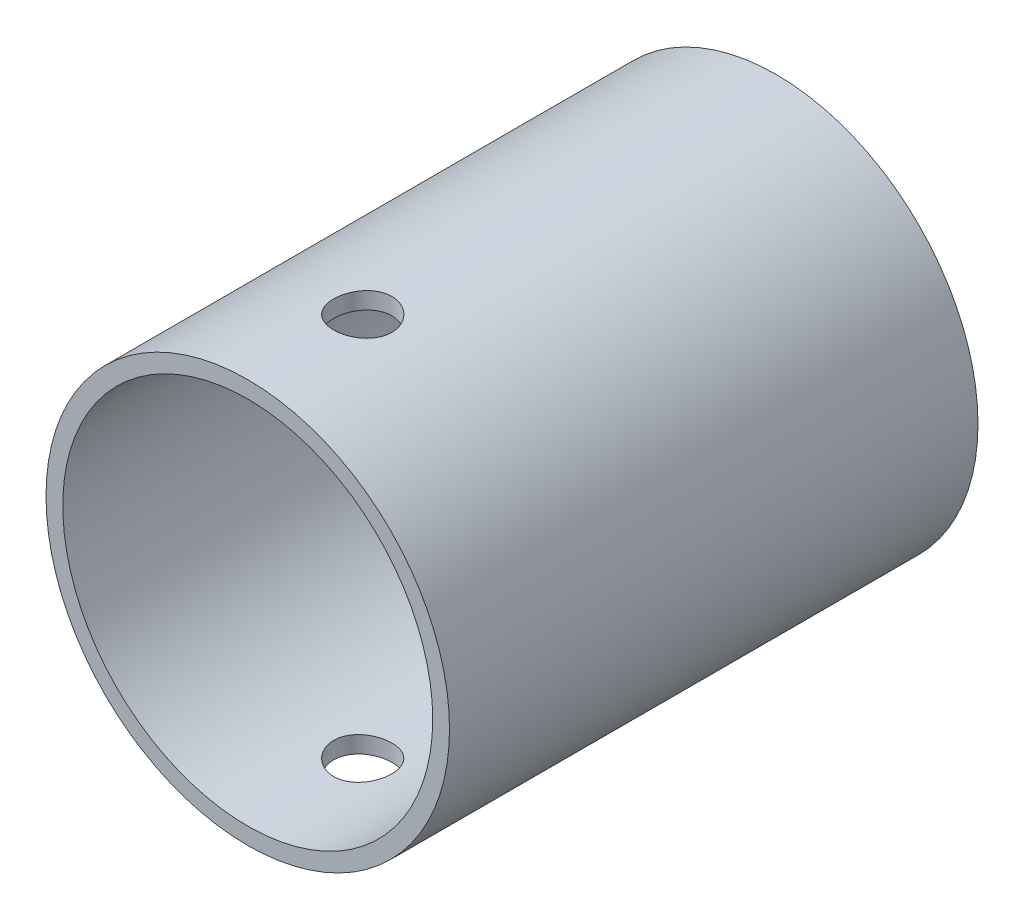
from build123d import *

# Parameters (mm, degrees)
SKETCH1_R           = 19.0875
SKETCH1_R_2         = 17.5
BOSS_EXTRUDE1_DEPTH = 50
SKETCH2_R           = 17.5
SKETCH2_R_2         = 6
BOSS_EXTRUDE2_DEPTH = 5
SKETCH3_R           = 17.5
SKETCH3_R_2         = 9
BOSS_EXTRUDE3_DEPTH = 1
SKETCH4_R           = 17.5
SKETCH4_R_2         = 10
BOSS_EXTRUDE4_DEPTH = 12
SKETCH7_W           = 2.75
SKETCH7_H           = 19.0875


with BuildPart() as part:
    # Sketch1 → Boss-Extrude1 (new body)
    with BuildSketch(Plane.XY):
        Circle(SKETCH1_R)
        Circle(SKETCH1_R_2, mode=Mode.SUBTRACT)
    extrude(amount=BOSS_EXTRUDE1_DEPTH)

    # Sketch2 → Boss-Extrude2 (add)
    with BuildSketch(Plane(origin=(0, 0, 0), x_dir=(-1, 0, 0), z_dir=(0, 0, -1))):
        Circle(SKETCH2_R)
        Circle(SKETCH2_R_2, mode=Mode.SUBTRACT)
    extrude(amount=-BOSS_EXTRUDE2_DEPTH)

    # Sketch3 → Boss-Extrude3 (add)
    with BuildSketch(Plane.XY.offset(5)):
        Circle(SKETCH3_R)
        Circle(SKETCH3_R_2, mode=Mode.SUBTRACT)
    extrude(amount=BOSS_EXTRUDE3_DEPTH)

    # Sketch4 → Boss-Extrude4 (add)
    with BuildSketch(Plane.XY.offset(6)):
        Circle(SKETCH4_R)
        Circle(SKETCH4_R_2, mode=Mode.SUBTRACT)
    extrude(amount=BOSS_EXTRUDE4_DEPTH)

    # Sketch7 → M5 Clearance Hole1 (revolve, cut)
    with BuildSketch(Plane(origin=(0, 0, 39.120000392), x_dir=(0, 0, -1), z_dir=(1, 0, 0))):
        with Locations((1.375, 9.54375)):
            Rectangle(SKETCH7_W, SKETCH7_H)
    m5_clearance_hole1 = revolve(axis=Axis((0, -6.35, 39.120000392), (0, 1, 0)), mode=Mode.SUBTRACT)

    # Mirror1: M5 Clearance Hole1 across plane
    add(m5_clearance_hole1.mirror(Plane.ZX), mode=Mode.SUBTRACT)


solid = part.part
